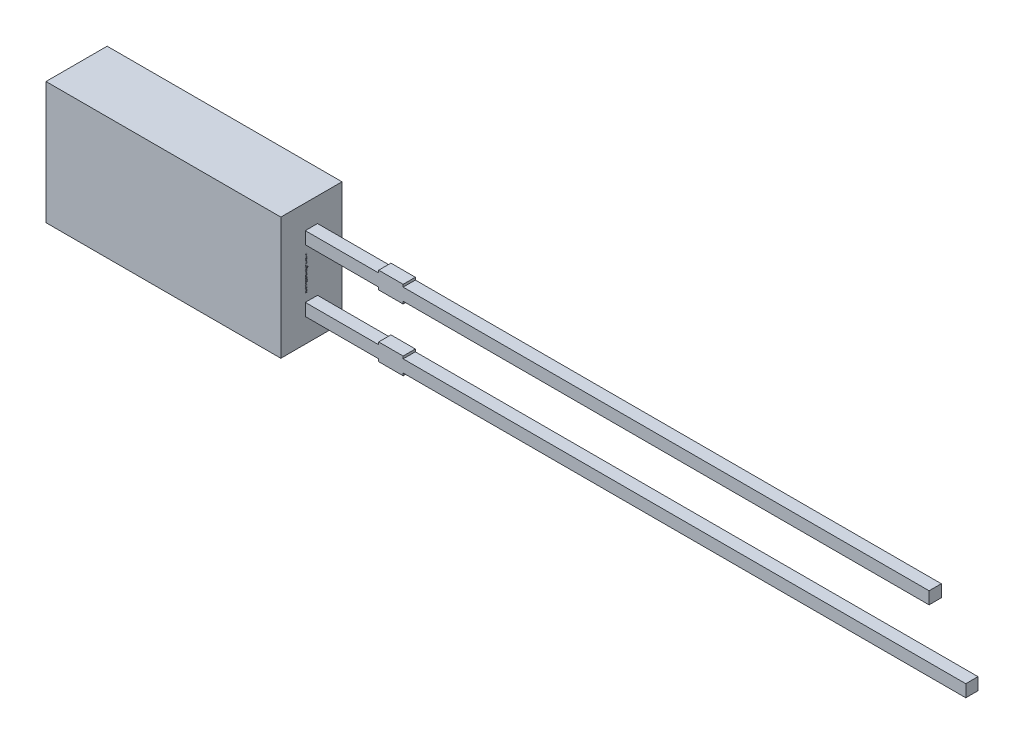
from build123d import *

# Parameters (mm, degrees)
SKETCH1_W          = 9.6
SKETCH1_H          = 5
EXTRUDE1_DEPTH     = 1.25
SKETCH1_4_W        = 3
SKETCH1_4_H        = 0.5
SKETCH1_4_W_2      = 1
SKETCH1_4_W_3      = 21.5
SKETCH1_4_H_2      = 0.1
SKETCH1_4_W_4      = 23
EXTRUDE2_DEPTH     = 0.25
SKETCH2_W          = 0.026582278
SKETCH2_H          = 0.025316456
CUT_EXTRUDE1_DEPTH = 0.01


with BuildPart() as part:
    # Sketch1 → Extrude1 (new body, symmetric)
    with BuildSketch(Plane.XY):
        Rectangle(SKETCH1_W, SKETCH1_H)
    extrude(amount=EXTRUDE1_DEPTH, both=True)

    # Sketch1_4 → Extrude2 (add, symmetric)
    with BuildSketch(Plane.XY):
        with Locations((6.3, 1.27)):
            Rectangle(SKETCH1_4_W, SKETCH1_4_H)
        with Locations((8.3, 1.27)):
            Rectangle(SKETCH1_4_W_2, SKETCH1_4_H)
        with Locations((19.55, 1.27)):
            Rectangle(SKETCH1_4_W_3, SKETCH1_4_H)
        with Locations((8.3, 1.57)):
            Rectangle(SKETCH1_4_W_2, SKETCH1_4_H_2)
        with Locations((8.3, 0.97)):
            Rectangle(SKETCH1_4_W_2, SKETCH1_4_H_2)
        with Locations((8.3, -1.27)):
            Rectangle(SKETCH1_4_W_2, SKETCH1_4_H)
        with Locations((8.3, -0.97)):
            Rectangle(SKETCH1_4_W_2, SKETCH1_4_H_2)
        with Locations((20.3, -1.27)):
            Rectangle(SKETCH1_4_W_4, SKETCH1_4_H)
        with Locations((6.3, -1.27)):
            Rectangle(SKETCH1_4_W, SKETCH1_4_H)
        with Locations((8.3, -1.57)):
            Rectangle(SKETCH1_4_W_2, SKETCH1_4_H_2)
    extrude(amount=EXTRUDE2_DEPTH, both=True)

    # Sketch2 → Cut-Extrude1 (cut)
    with BuildSketch(Plane(origin=(4.8, 0, 0), x_dir=(0, 0, -1), z_dir=(1, 0, 0))):
        Polygon((-0.175316456, 0.572151899), (-0.25, 0.595609177), (-0.25, 0.620352057), (-0.199663766, 0.636768196), (-0.25, 0.652294304), (-0.25, 0.678026108), (-0.175316456, 0.701265823), (-0.175316456, 0.676087816), (-0.226799842, 0.663093354), (-0.175316456, 0.646677215), (-0.175316456, 0.625178006), (-0.226799842, 0.608860759), (-0.175316456, 0.596044304), align=None)
        Polygon((-0.175316456, 0.437974684), (-0.25, 0.461431962), (-0.25, 0.486174842), (-0.199663766, 0.502590981), (-0.25, 0.518117089), (-0.25, 0.543848892), (-0.175316456, 0.567088608), (-0.175316456, 0.541910601), (-0.226799842, 0.528916139), (-0.175316456, 0.5125), (-0.175316456, 0.491000791), (-0.226799842, 0.474683544), (-0.175316456, 0.461867089), align=None)
        Polygon((-0.175316456, 0.303797468), (-0.25, 0.327254747), (-0.25, 0.351997627), (-0.199663766, 0.368413766), (-0.25, 0.383939873), (-0.25, 0.409671677), (-0.175316456, 0.432911392), (-0.175316456, 0.407733386), (-0.226799842, 0.394738924), (-0.175316456, 0.378322785), (-0.175316456, 0.356823576), (-0.226799842, 0.340506329), (-0.175316456, 0.327689873), align=None)
        with Locations((-0.236708861, 0.275949367)):
            Rectangle(SKETCH2_W, SKETCH2_H)
        with BuildLine():
            add(Edge.make_bspline(
                [(-0.218829114, 0.159493671), (-0.220051248, 0.159530169), (-0.22245111, 0.15960184), (-0.225958798, 0.160211426), (-0.229283102, 0.161205393), (-0.232447248, 0.162577732), (-0.235416736, 0.164371189), (-0.238219628, 0.16655446), (-0.240824172, 0.169143343), (-0.243260547, 0.172090146), (-0.245442658, 0.175387089), (-0.247348691, 0.178984804), (-0.248943362, 0.18286483), (-0.250282428, 0.187013042), (-0.251270861, 0.191459588), (-0.251994849, 0.196177087), (-0.252468166, 0.201170514), (-0.252510134, 0.204594091), (-0.252531646, 0.206348892)],
                knots=[0, 0, 0, 0, 0.907312236, 1.78165839, 2.635367075, 3.479697475, 4.336364812, 5.205276731, 6.11257575, 7.058770404, 8.040786331, 9.044147278, 10.078219212, 11.153049307, 12.278104542, 13.457648573, 14.696882856, 16, 16, 16, 16], degree=3))
            add(Edge.make_bspline(
                [(-0.252531646, 0.206348892), (-0.252507574, 0.208367148), (-0.252460949, 0.21227633), (-0.25203235, 0.217939855), (-0.251386211, 0.223207892), (-0.250419669, 0.228103607), (-0.249218904, 0.232708206), (-0.247927612, 0.237141474), (-0.246463197, 0.241422786), (-0.245363039, 0.244195876), (-0.244818038, 0.24556962)],
                knots=[0, 0, 0, 0, 1.203215828, 2.33052265, 3.384689099, 4.366106119, 5.303329643, 6.221311756, 7.118865988, 8, 8, 8, 8], degree=3))
            Line((-0.244818038, 0.24556962), (-0.220886076, 0.24556962))
            Line((-0.220886076, 0.24556962), (-0.220886076, 0.242721519))
            add(Edge.make_bspline(
                [(-0.220886076, 0.242721519), (-0.221967531, 0.241356205), (-0.224124092, 0.238633592), (-0.226886697, 0.234200359), (-0.22928886, 0.229552713), (-0.231262862, 0.224707243), (-0.232849186, 0.219810398), (-0.233942713, 0.21493502), (-0.234690062, 0.210169433), (-0.234770569, 0.207010864), (-0.234810127, 0.205458861)],
                knots=[0, 0, 0, 0, 1.030622468, 2.055194264, 3.087043286, 4.125157485, 5.149848264, 6.130935704, 7.081611712, 8, 8, 8, 8], degree=3))
            add(Edge.make_bspline(
                [(-0.234810127, 0.205458861), (-0.234809232, 0.205030082), (-0.234807317, 0.2041121), (-0.234678474, 0.202644063), (-0.234585311, 0.200985464), (-0.234376093, 0.199206598), (-0.23415751, 0.197415781), (-0.23377719, 0.195761121), (-0.233415351, 0.194257482), (-0.233047173, 0.193351), (-0.232871835, 0.192919304)],
                knots=[0, 0, 0, 0, 0.806378557, 1.726393851, 2.771014456, 3.931269413, 5.096090628, 6.161710732, 7.124547685, 8, 8, 8, 8], degree=3))
            add(Edge.make_bspline(
                [(-0.232871835, 0.192919304), (-0.232644012, 0.192439517), (-0.23219629, 0.191496634), (-0.231378683, 0.190201714), (-0.230507381, 0.189019042), (-0.229541962, 0.187957582), (-0.228364053, 0.187107314), (-0.226963197, 0.186479113), (-0.225312897, 0.186136019), (-0.224137886, 0.186096725), (-0.223516614, 0.186075949)],
                knots=[0, 0, 0, 0, 1.024407818, 2.013179384, 2.949802342, 3.859052226, 4.77034807, 5.732977883, 6.801339628, 8, 8, 8, 8], degree=3))
            add(Edge.make_bspline(
                [(-0.223516614, 0.186075949), (-0.222970718, 0.186107391), (-0.221897325, 0.186169215), (-0.220369329, 0.186751006), (-0.218947452, 0.187633905), (-0.217686737, 0.188920927), (-0.216529299, 0.190515003), (-0.215559002, 0.19247074), (-0.214678928, 0.194723719), (-0.214261659, 0.196368178), (-0.214042722, 0.197231013)],
                knots=[0, 0, 0, 0, 0.825212765, 1.622611382, 2.449701629, 3.348069183, 4.336544339, 5.428209675, 6.6506027, 8, 8, 8, 8], degree=3))
            add(Edge.make_bspline(
                [(-0.214042722, 0.197231013), (-0.213594981, 0.19919974), (-0.212677791, 0.203232648), (-0.211530684, 0.209380757), (-0.210264611, 0.215510984), (-0.20905507, 0.219469696), (-0.20846519, 0.221400316)],
                knots=[0, 0, 0, 0, 0.976104583, 1.999535498, 3.024395274, 4, 4, 4, 4], degree=3))
            add(Edge.make_bspline(
                [(-0.20846519, 0.221400316), (-0.208112197, 0.222438832), (-0.207425064, 0.224460401), (-0.206263439, 0.227351945), (-0.204993487, 0.230013057), (-0.203638356, 0.232453168), (-0.202164358, 0.23465249), (-0.200630968, 0.236647679), (-0.198977131, 0.238391205), (-0.197245211, 0.239938889), (-0.195393209, 0.241262203), (-0.193449072, 0.242416954), (-0.191388607, 0.243392589), (-0.189227318, 0.244201473), (-0.18694845, 0.244818545), (-0.184571576, 0.245239801), (-0.182088216, 0.24553819), (-0.180393863, 0.245559001), (-0.179529272, 0.24556962)],
                knots=[0, 0, 0, 0, 1.287286806, 2.505824366, 3.654938963, 4.74627059, 5.778586806, 6.75996495, 7.696030012, 8.595059759, 9.482019644, 10.363222407, 11.245851011, 12.154256429, 13.068444161, 14.012503255, 14.985824751, 16, 16, 16, 16], degree=3))
            add(Edge.make_bspline(
                [(-0.179529272, 0.24556962), (-0.178373127, 0.245532318), (-0.176097855, 0.245458909), (-0.172768811, 0.24485748), (-0.169620074, 0.24383089), (-0.166616611, 0.242444827), (-0.163803525, 0.240616199), (-0.161124978, 0.238431404), (-0.158653386, 0.235807357), (-0.156353053, 0.232830235), (-0.154273654, 0.229542851), (-0.152443098, 0.226003867), (-0.150906446, 0.222234578), (-0.149632552, 0.218249032), (-0.148677881, 0.214030563), (-0.14795895, 0.20959333), (-0.147545768, 0.204919541), (-0.147494518, 0.20172812), (-0.147468354, 0.200098892)],
                knots=[0, 0, 0, 0, 0.894990994, 1.761326291, 2.609044902, 3.454222546, 4.315366365, 5.200560057, 6.125081389, 7.100429509, 8.110379559, 9.133447974, 10.182136699, 11.259192205, 12.370181258, 13.528580438, 14.738335141, 16, 16, 16, 16], degree=3))
            add(Edge.make_bspline(
                [(-0.147468354, 0.200098892), (-0.147490546, 0.198430205), (-0.147534891, 0.19509566), (-0.147912869, 0.190114218), (-0.148468097, 0.185153716), (-0.149309803, 0.180289886), (-0.15028622, 0.175599331), (-0.151382015, 0.171186095), (-0.15261998, 0.167106634), (-0.153574325, 0.16453297), (-0.15403481, 0.163291139)],
                knots=[0, 0, 0, 0, 1.065403572, 2.129000689, 3.188532477, 4.251604565, 5.279552602, 6.247508681, 7.154397237, 8, 8, 8, 8], degree=3))
            Line((-0.15403481, 0.163291139), (-0.176582278, 0.163291139))
            Line((-0.176582278, 0.163291139), (-0.176582278, 0.166119462))
            add(Edge.make_bspline(
                [(-0.176582278, 0.166119462), (-0.175781932, 0.167192367), (-0.174145202, 0.169386485), (-0.17206153, 0.173046122), (-0.170103664, 0.177004358), (-0.168419505, 0.181283188), (-0.166960024, 0.185742216), (-0.165940858, 0.190325174), (-0.165299048, 0.194951338), (-0.165226273, 0.198053049), (-0.165189873, 0.19960443)],
                knots=[0, 0, 0, 0, 0.892283326, 1.824742884, 2.804416662, 3.836872171, 4.8899239, 5.931447339, 6.965372909, 8, 8, 8, 8], degree=3))
            add(Edge.make_bspline(
                [(-0.165189873, 0.19960443), (-0.165211326, 0.200700098), (-0.165254228, 0.202891315), (-0.165644912, 0.206159523), (-0.166275806, 0.209401584), (-0.167095088, 0.211442107), (-0.167503956, 0.212460443)],
                knots=[0, 0, 0, 0, 0.999146175, 1.998183711, 3.000980573, 4, 4, 4, 4], degree=3))
            add(Edge.make_bspline(
                [(-0.167503956, 0.212460443), (-0.167705423, 0.212893946), (-0.168108222, 0.213760664), (-0.168880786, 0.214967308), (-0.169809597, 0.216071977), (-0.170861589, 0.217064055), (-0.172017962, 0.217932452), (-0.173292788, 0.218547803), (-0.174655703, 0.218923676), (-0.175590934, 0.218965835), (-0.176068038, 0.218987342)],
                knots=[0, 0, 0, 0, 1.00524851, 2.009826503, 3.004679593, 4.035271301, 5.048246368, 6.034938417, 6.997532266, 8, 8, 8, 8], degree=3))
            add(Edge.make_bspline(
                [(-0.176068038, 0.218987342), (-0.176706203, 0.218952904), (-0.177925679, 0.218887095), (-0.179641475, 0.218280511), (-0.181119909, 0.217295678), (-0.182114829, 0.216135073), (-0.182812267, 0.215017943), (-0.183322777, 0.213982284), (-0.183806136, 0.212773057), (-0.184303605, 0.211401809), (-0.184794792, 0.209865482), (-0.185270339, 0.208156925), (-0.185719635, 0.206274208), (-0.186005825, 0.204958333), (-0.186155063, 0.204272152)],
                knots=[0, 0, 0, 0, 1.173816843, 2.243057204, 3.312297565, 4.415174738, 5.03266065, 5.73970059, 6.541434878, 7.433956553, 8.430083051, 9.515931566, 10.70464786, 12, 12, 12, 12], degree=3))
            add(Edge.make_bspline(
                [(-0.186155063, 0.204272152), (-0.186531125, 0.202439363), (-0.187270003, 0.198838337), (-0.188373491, 0.193437153), (-0.18964846, 0.18793438), (-0.190797263, 0.184269053), (-0.191396361, 0.182357595)],
                knots=[0, 0, 0, 0, 0.995744513, 1.956417928, 2.934277412, 4, 4, 4, 4], degree=3))
            add(Edge.make_bspline(
                [(-0.191396361, 0.182357595), (-0.191715605, 0.181411041), (-0.192340097, 0.179559428), (-0.19342638, 0.176918797), (-0.194600363, 0.174471738), (-0.195841894, 0.172204706), (-0.19718586, 0.170130736), (-0.198608507, 0.168236053), (-0.200135416, 0.166552235), (-0.201748644, 0.16505467), (-0.203458744, 0.16373551), (-0.205297817, 0.162603212), (-0.207246619, 0.161630984), (-0.209332819, 0.160861379), (-0.211527406, 0.160243358), (-0.213858774, 0.159820261), (-0.21630315, 0.159526278), (-0.217977728, 0.159504661), (-0.218829114, 0.159493671)],
                knots=[0, 0, 0, 0, 1.237467875, 2.420686895, 3.535046182, 4.599015201, 5.620884487, 6.594603852, 7.531477383, 8.433220087, 9.318759595, 10.202828513, 11.105163009, 12.01247538, 12.953896178, 13.926381251, 14.945733412, 16, 16, 16, 16], degree=3))
        make_face()
        with BuildLine():
            Line((-0.25, 0.067088608), (-0.25, 0.091139241))
            Line((-0.25, 0.091139241), (-0.242167722, 0.091139241))
            add(Edge.make_bspline(
                [(-0.242167722, 0.091139241), (-0.24297628, 0.092232549), (-0.244535168, 0.094340433), (-0.246615386, 0.097513458), (-0.248390652, 0.100539548), (-0.249949873, 0.103453039), (-0.251125258, 0.106475242), (-0.251953324, 0.109706756), (-0.252453097, 0.113209581), (-0.252504881, 0.115636475), (-0.252531646, 0.116890823)],
                knots=[0, 0, 0, 0, 1.150872466, 2.218865267, 3.209461834, 4.120482262, 5.012764827, 5.946708227, 6.938749913, 8, 8, 8, 8], degree=3))
            add(Edge.make_bspline(
                [(-0.252531646, 0.116890823), (-0.252508927, 0.117907175), (-0.252464686, 0.119886305), (-0.252119808, 0.122763545), (-0.251582157, 0.125471173), (-0.250774566, 0.127986213), (-0.249808763, 0.130350202), (-0.248528805, 0.132487752), (-0.247098631, 0.134491354), (-0.245391585, 0.136273026), (-0.243493852, 0.137888648), (-0.241361392, 0.139271198), (-0.239028466, 0.140448909), (-0.236476612, 0.141390006), (-0.233718309, 0.142145096), (-0.230739061, 0.142669028), (-0.227551934, 0.142989621), (-0.225356803, 0.14302156), (-0.224228639, 0.143037975)],
                knots=[0, 0, 0, 0, 1.109008058, 2.159558935, 3.158726032, 4.116861086, 5.039058877, 5.938775559, 6.82970133, 7.720510853, 8.624361809, 9.544451588, 10.487360536, 11.471068125, 12.508000841, 13.604731202, 14.768976642, 16, 16, 16, 16], degree=3))
            Line((-0.224228639, 0.143037975), (-0.175316456, 0.143037975))
            Line((-0.175316456, 0.143037975), (-0.175316456, 0.118987342))
            Line((-0.175316456, 0.118987342), (-0.21289557, 0.118987342))
            add(Edge.make_bspline(
                [(-0.21289557, 0.118987342), (-0.213812041, 0.118985706), (-0.215566256, 0.118982576), (-0.218072063, 0.118900237), (-0.220340235, 0.118779336), (-0.222382264, 0.118640631), (-0.224229015, 0.118387615), (-0.225895176, 0.118009906), (-0.227414778, 0.11753908), (-0.228321479, 0.117074761), (-0.228757911, 0.116851266)],
                knots=[0, 0, 0, 0, 1.361401701, 2.605856924, 3.723918663, 4.735739235, 5.645738665, 6.489217889, 7.27279937, 8, 8, 8, 8], degree=3))
            add(Edge.make_bspline(
                [(-0.228757911, 0.116851266), (-0.229156626, 0.116621259), (-0.229940466, 0.116169086), (-0.230946644, 0.115248796), (-0.231790911, 0.114170053), (-0.23244694, 0.112892449), (-0.232945889, 0.111405901), (-0.233286125, 0.109677971), (-0.233501627, 0.107692609), (-0.233529535, 0.106283591), (-0.233544304, 0.105537975)],
                knots=[0, 0, 0, 0, 0.849138082, 1.669332372, 2.503455908, 3.370611167, 4.311442699, 5.394692208, 6.621337967, 8, 8, 8, 8], degree=3))
            add(Edge.make_bspline(
                [(-0.233544304, 0.105537975), (-0.233526947, 0.104996691), (-0.233491259, 0.103883773), (-0.233258814, 0.102172461), (-0.232902139, 0.100375884), (-0.232242283, 0.097861301), (-0.231056104, 0.094694674), (-0.229701697, 0.092335372), (-0.229015032, 0.091139241)],
                knots=[0, 0, 0, 0, 0.638127216, 1.312033637, 2.033062677, 2.79661882, 4.375931797, 6, 6, 6, 6], degree=3))
            Line((-0.229015032, 0.091139241), (-0.175316456, 0.091139241))
            Line((-0.175316456, 0.091139241), (-0.175316456, 0.067088608))
            Line((-0.175316456, 0.067088608), (-0.25, 0.067088608))
        make_face()
        with BuildLine():
            Line((-0.25, -0.030379747), (-0.25, -0.006329114))
            Line((-0.25, -0.006329114), (-0.212420886, -0.006329114))
            add(Edge.make_bspline(
                [(-0.212420886, -0.006329114), (-0.210890843, -0.0063046), (-0.207839818, -0.006255716), (-0.204077407, -0.005973592), (-0.201235083, -0.00559507), (-0.199397202, -0.005225415), (-0.197849063, -0.004793715), (-0.196963303, -0.004381435), (-0.196558544, -0.004193038)],
                knots=[0, 0, 0, 0, 1.709124929, 3.408128882, 4.211124727, 4.91016634, 5.501986363, 6, 6, 6, 6], degree=3))
            add(Edge.make_bspline(
                [(-0.196558544, -0.004193038), (-0.196160491, -0.003948575), (-0.195380051, -0.003469272), (-0.194367038, -0.002531948), (-0.193538197, -0.001438061), (-0.192856647, -0.000167292), (-0.192386066, 0.001323905), (-0.191992836, 0.003040645), (-0.191825927, 0.005027263), (-0.191790767, 0.006434533), (-0.191772152, 0.007179589)],
                knots=[0, 0, 0, 0, 0.86006424, 1.686277094, 2.52783008, 3.38194165, 4.331801563, 5.402842185, 6.624978739, 8, 8, 8, 8], degree=3))
            add(Edge.make_bspline(
                [(-0.191772152, 0.007179589), (-0.191828889, 0.00831141), (-0.191944743, 0.010622505), (-0.19265625, 0.013484698), (-0.193475209, 0.015815302), (-0.19423404, 0.017667827), (-0.195205482, 0.019576457), (-0.195927304, 0.020855869), (-0.196301424, 0.021518987)],
                knots=[0, 0, 0, 0, 1.338371478, 2.732853438, 3.468019217, 4.261884641, 5.099136535, 6, 6, 6, 6], degree=3))
            Line((-0.196301424, 0.021518987), (-0.25, 0.021518987))
            Line((-0.25, 0.021518987), (-0.25, 0.04556962))
            Line((-0.25, 0.04556962), (-0.175316456, 0.04556962))
            Line((-0.175316456, 0.04556962), (-0.175316456, 0.021518987))
            Line((-0.175316456, 0.021518987), (-0.183148734, 0.021518987))
            add(Edge.make_bspline(
                [(-0.183148734, 0.021518987), (-0.182342583, 0.020461581), (-0.18077336, 0.018403276), (-0.17873294, 0.015224038), (-0.176934171, 0.01214014), (-0.175421354, 0.009087131), (-0.174214579, 0.005972176), (-0.17340359, 0.002709417), (-0.172859787, -0.000706989), (-0.172810094, -0.003043704), (-0.17278481, -0.004232595)],
                knots=[0, 0, 0, 0, 1.126119141, 2.192057864, 3.198061997, 4.149848529, 5.076251285, 6.021887753, 6.99356175, 8, 8, 8, 8], degree=3))
            add(Edge.make_bspline(
                [(-0.17278481, -0.004232595), (-0.172810199, -0.005228866), (-0.172859763, -0.007173765), (-0.173169473, -0.010008526), (-0.173720137, -0.012679947), (-0.174517966, -0.015172221), (-0.175503578, -0.017514841), (-0.176735093, -0.019676785), (-0.178193516, -0.021668856), (-0.179854519, -0.023497257), (-0.181744245, -0.025128075), (-0.18386151, -0.026545111), (-0.186204606, -0.027725092), (-0.188764915, -0.028695805), (-0.191530024, -0.029470228), (-0.19452599, -0.029985359), (-0.197730169, -0.030339143), (-0.199946212, -0.030365941), (-0.201087816, -0.030379747)],
                knots=[0, 0, 0, 0, 1.08848837, 2.124922927, 3.110950502, 4.063144162, 4.979605775, 5.882838355, 6.774625441, 7.671951181, 8.57587277, 9.494821853, 10.448322275, 11.435533005, 12.482327682, 13.580118324, 14.753386918, 16, 16, 16, 16], degree=3))
            Line((-0.201087816, -0.030379747), (-0.25, -0.030379747))
        make_face()
        Polygon((-0.25, -0.125316456), (-0.25, -0.053164557), (-0.15, -0.053164557), (-0.15, -0.078481013), (-0.231012658, -0.078481013), (-0.231012658, -0.125316456), align=None)
        Polygon((-0.25, -0.212658228), (-0.25, -0.140506329), (-0.15, -0.140506329), (-0.15, -0.212658228), (-0.168987342, -0.212658228), (-0.168987342, -0.165822785), (-0.186708861, -0.165822785), (-0.186708861, -0.208860759), (-0.205696203, -0.208860759), (-0.205696203, -0.165822785), (-0.231012658, -0.165822785), (-0.231012658, -0.212658228), align=None)
        with BuildLine():
            add(Edge.make_bspline(
                [(-0.200098892, -0.329113924), (-0.201246581, -0.329094609), (-0.203519467, -0.329056357), (-0.206884274, -0.328761165), (-0.210149949, -0.32823514), (-0.213334198, -0.327555959), (-0.216413126, -0.326633453), (-0.219420703, -0.325551739), (-0.222326196, -0.324242093), (-0.225127631, -0.322737241), (-0.227799734, -0.321087768), (-0.230319942, -0.319313019), (-0.23270316, -0.31746724), (-0.234898054, -0.315477927), (-0.236940074, -0.313398746), (-0.238830888, -0.311223217), (-0.240534319, -0.308918153), (-0.241557203, -0.30731099), (-0.242068829, -0.30650712)],
                knots=[0, 0, 0, 0, 1.105570398, 2.18947457, 3.250358341, 4.290584537, 5.323553275, 6.344225964, 7.367641686, 8.3905646, 9.405808457, 10.390761353, 11.358902336, 12.307789878, 13.241960776, 14.165076779, 15.082208636, 16, 16, 16, 16], degree=3))
            add(Edge.make_bspline(
                [(-0.242068829, -0.30650712), (-0.242780968, -0.305267892), (-0.244208881, -0.302783112), (-0.245877472, -0.298799278), (-0.247281588, -0.294673795), (-0.248336012, -0.290323409), (-0.249063056, -0.285676399), (-0.249623862, -0.28067499), (-0.249925622, -0.275267401), (-0.249974642, -0.271532506), (-0.25, -0.269600475)],
                knots=[0, 0, 0, 0, 0.896288622, 1.797150563, 2.705281913, 3.629615989, 4.602417572, 5.655716007, 6.787320449, 8, 8, 8, 8], degree=3))
            Line((-0.25, -0.269600475), (-0.25, -0.234177215))
            Line((-0.25, -0.234177215), (-0.15, -0.234177215))
            Line((-0.15, -0.234177215), (-0.15, -0.270609177))
            add(Edge.make_bspline(
                [(-0.15, -0.270609177), (-0.150016611, -0.272587909), (-0.150048652, -0.276404637), (-0.150466242, -0.281921476), (-0.151063066, -0.287026684), (-0.151987937, -0.291712032), (-0.153103282, -0.296012037), (-0.154462411, -0.299937513), (-0.155961118, -0.303549287), (-0.157234811, -0.305728129), (-0.157852057, -0.306784019)],
                knots=[0, 0, 0, 0, 1.267175336, 2.444223962, 3.542125549, 4.557526608, 5.500936977, 6.385043188, 7.217374394, 8, 8, 8, 8], degree=3))
            add(Edge.make_bspline(
                [(-0.157852057, -0.306784019), (-0.158388598, -0.307634972), (-0.159455511, -0.309327097), (-0.161237363, -0.311728312), (-0.16319344, -0.313957739), (-0.165245259, -0.316086242), (-0.167448146, -0.318066059), (-0.169786853, -0.319909259), (-0.172264947, -0.321613076), (-0.174874416, -0.323171039), (-0.177604468, -0.324591854), (-0.180477527, -0.32578116), (-0.183456057, -0.326830509), (-0.186565019, -0.327636046), (-0.189772856, -0.32833396), (-0.1931142, -0.328768694), (-0.196566688, -0.329055305), (-0.198911578, -0.32909422), (-0.200098892, -0.329113924)],
                knots=[0, 0, 0, 0, 0.964065863, 1.917049184, 2.86229036, 3.805247319, 4.749389377, 5.698846072, 6.657678277, 7.629829384, 8.610569287, 9.604676042, 10.607940105, 11.6349849, 12.681042988, 13.752616828, 14.862056989, 16, 16, 16, 16], degree=3))
        make_face()
        with BuildLine():
            add(Edge.make_bspline(
                [(-0.199940665, -0.302531646), (-0.199135905, -0.302521405), (-0.197557321, -0.302501317), (-0.195241806, -0.30230975), (-0.193012156, -0.302050694), (-0.190877464, -0.30161964), (-0.188817893, -0.301119993), (-0.186860399, -0.300477843), (-0.184980826, -0.299753447), (-0.183203337, -0.298871809), (-0.181494955, -0.297898172), (-0.17990944, -0.296750679), (-0.178396553, -0.295502341), (-0.176968569, -0.294124054), (-0.175662673, -0.292581114), (-0.174432597, -0.290921012), (-0.173304271, -0.289120654), (-0.172644221, -0.287847665), (-0.172310127, -0.287203323)],
                knots=[0, 0, 0, 0, 1.152093354, 2.259898929, 3.325467225, 4.364140538, 5.376172865, 6.358396836, 7.312077728, 8.257828931, 9.196960457, 10.124297759, 11.056236784, 12.004246951, 12.961658638, 13.947279359, 14.960983522, 16, 16, 16, 16], degree=3))
            add(Edge.make_bspline(
                [(-0.172310127, -0.287203323), (-0.172003415, -0.286528425), (-0.17139549, -0.285190731), (-0.170664298, -0.283119908), (-0.170091462, -0.281030524), (-0.169660604, -0.278828925), (-0.169338673, -0.276359165), (-0.169141415, -0.273433583), (-0.168999245, -0.269977674), (-0.168991494, -0.267490959), (-0.168987342, -0.266159019)],
                knots=[0, 0, 0, 0, 0.826967603, 1.639107464, 2.447640171, 3.242670507, 4.14065217, 5.225198036, 6.513753944, 8, 8, 8, 8], degree=3))
            Line((-0.168987342, -0.266159019), (-0.168987342, -0.259493671))
            Line((-0.168987342, -0.259493671), (-0.231012658, -0.259493671))
            Line((-0.231012658, -0.259493671), (-0.231012658, -0.266159019))
            add(Edge.make_bspline(
                [(-0.231012658, -0.266159019), (-0.231007909, -0.266917226), (-0.230998739, -0.268380991), (-0.230955677, -0.270497235), (-0.230908789, -0.272463031), (-0.230792327, -0.274267902), (-0.230719681, -0.275926587), (-0.230541302, -0.277413368), (-0.230399122, -0.278755857), (-0.230131399, -0.280323454), (-0.229715216, -0.28217662), (-0.229037037, -0.28433788), (-0.228186642, -0.286478414), (-0.227501675, -0.287866987), (-0.227155854, -0.288568038)],
                knots=[0, 0, 0, 0, 1.186793418, 2.291178421, 3.313283093, 4.264083014, 5.122158624, 5.910777728, 6.607099052, 7.234812932, 8.398911528, 9.577194775, 10.776795607, 12, 12, 12, 12], degree=3))
            add(Edge.make_bspline(
                [(-0.227155854, -0.288568038), (-0.226814338, -0.289153154), (-0.226140824, -0.29030708), (-0.22500675, -0.291930584), (-0.223799025, -0.293438302), (-0.222510574, -0.294834314), (-0.221122333, -0.296097614), (-0.219655791, -0.297249633), (-0.218107813, -0.298280082), (-0.215914295, -0.299515471), (-0.212883358, -0.300738716), (-0.208915972, -0.301778259), (-0.204556209, -0.30241513), (-0.201518591, -0.302491812), (-0.199940665, -0.302531646)],
                knots=[0, 0, 0, 0, 0.755160452, 1.489275589, 2.205657296, 2.907868421, 3.605098304, 4.296256403, 4.985378686, 5.676536785, 7.100390329, 8.614249252, 10.241231541, 12, 12, 12, 12], degree=3))
        make_face(mode=Mode.SUBTRACT)
        with Locations((-0.236708861, -0.360759494)):
            Rectangle(SKETCH2_W, SKETCH2_H)
        with BuildLine():
            add(Edge.make_bspline(
                [(-0.252531646, -0.435403481), (-0.252509834, -0.433813368), (-0.252467023, -0.430692232), (-0.251990106, -0.42612089), (-0.25127241, -0.421755717), (-0.250251504, -0.417609409), (-0.248904008, -0.413695618), (-0.247251072, -0.41003198), (-0.245265888, -0.406625123), (-0.243686679, -0.404566476), (-0.242899525, -0.403540348)],
                knots=[0, 0, 0, 0, 1.123670284, 2.205584497, 3.245308791, 4.249063313, 5.220352711, 6.167273909, 7.086481357, 8, 8, 8, 8], degree=3))
            add(Edge.make_bspline(
                [(-0.242899525, -0.403540348), (-0.242044751, -0.402588601), (-0.240338508, -0.400688786), (-0.237367081, -0.398222853), (-0.234084037, -0.396099767), (-0.230481815, -0.394314215), (-0.226565086, -0.392883291), (-0.222320424, -0.391860157), (-0.217759643, -0.391240912), (-0.21461171, -0.391173746), (-0.212994462, -0.391139241)],
                knots=[0, 0, 0, 0, 0.916457077, 1.82937027, 2.759194969, 3.714948755, 4.706655623, 5.743329475, 6.840637961, 8, 8, 8, 8], degree=3))
            add(Edge.make_bspline(
                [(-0.212994462, -0.391139241), (-0.211291235, -0.391178001), (-0.207990155, -0.391253124), (-0.203217967, -0.391916883), (-0.198800287, -0.392986496), (-0.194748378, -0.394524054), (-0.191055187, -0.396454496), (-0.187683352, -0.398718989), (-0.184640428, -0.401339514), (-0.182894988, -0.403346653), (-0.182021361, -0.404351266)],
                knots=[0, 0, 0, 0, 1.171797512, 2.271099083, 3.308930235, 4.294129479, 5.24602549, 6.17106565, 7.084581485, 8, 8, 8, 8], degree=3))
            add(Edge.make_bspline(
                [(-0.182021361, -0.404351266), (-0.181252774, -0.405377136), (-0.179706318, -0.407441268), (-0.177805619, -0.410844773), (-0.176210833, -0.414467988), (-0.174963188, -0.418297559), (-0.174009283, -0.422270367), (-0.173285439, -0.426330027), (-0.172864881, -0.43047628), (-0.172811629, -0.43326648), (-0.17278481, -0.434671677)],
                knots=[0, 0, 0, 0, 0.952130878, 1.915761808, 2.890227217, 3.891541892, 4.905612075, 5.925811839, 6.955400088, 8, 8, 8, 8], degree=3))
            add(Edge.make_bspline(
                [(-0.17278481, -0.434671677), (-0.172801812, -0.435918396), (-0.172835245, -0.438369867), (-0.173157354, -0.441970914), (-0.173690473, -0.445425455), (-0.174429076, -0.448730387), (-0.175320679, -0.451904334), (-0.17635982, -0.454954511), (-0.177493088, -0.457914321), (-0.178377623, -0.45981489), (-0.178817247, -0.460759494)],
                knots=[0, 0, 0, 0, 1.107648782, 2.178012834, 3.209595929, 4.211695017, 5.185427128, 6.137685403, 7.07440854, 8, 8, 8, 8], degree=3))
            Line((-0.178817247, -0.460759494), (-0.199367089, -0.460759494))
            Line((-0.199367089, -0.460759494), (-0.199367089, -0.45741693))
            add(Edge.make_bspline(
                [(-0.199367089, -0.45741693), (-0.198949869, -0.456917386), (-0.198048154, -0.45583775), (-0.196627402, -0.454051335), (-0.195097809, -0.451902393), (-0.194205863, -0.450248857), (-0.193730222, -0.449367089)],
                knots=[0, 0, 0, 0, 0.792826818, 1.713491785, 2.780691913, 4, 4, 4, 4], degree=3))
            add(Edge.make_bspline(
                [(-0.193730222, -0.449367089), (-0.193288264, -0.448439154), (-0.192382404, -0.446537209), (-0.19154957, -0.443981204), (-0.190981844, -0.441789202), (-0.190725422, -0.439971666), (-0.190535861, -0.438038046), (-0.190516354, -0.436702803), (-0.190506329, -0.436016614)],
                knots=[0, 0, 0, 0, 1.332524827, 2.731214173, 3.480270227, 4.267952375, 5.109889624, 6, 6, 6, 6], degree=3))
            add(Edge.make_bspline(
                [(-0.190506329, -0.436016614), (-0.190525879, -0.435251058), (-0.190563765, -0.433767448), (-0.190840821, -0.431605939), (-0.191319079, -0.429587528), (-0.191959179, -0.427684306), (-0.192846792, -0.425946243), (-0.193880429, -0.424319403), (-0.195106231, -0.422827143), (-0.196547173, -0.421507882), (-0.198127102, -0.420315156), (-0.199861217, -0.419295954), (-0.201707816, -0.418383498), (-0.203712265, -0.41768856), (-0.205841041, -0.417128822), (-0.208104161, -0.416739892), (-0.210503671, -0.416497934), (-0.212149979, -0.416470016), (-0.212994462, -0.416455696)],
                knots=[0, 0, 0, 0, 1.087302107, 2.107140881, 3.088415001, 4.030197574, 4.951552271, 5.852940509, 6.764198256, 7.685219758, 8.621679636, 9.570836121, 10.538340132, 11.542450476, 12.578202196, 13.66207107, 14.800746211, 16, 16, 16, 16], degree=3))
            add(Edge.make_bspline(
                [(-0.212994462, -0.416455696), (-0.213858618, -0.416470471), (-0.215537631, -0.416499177), (-0.217979242, -0.416732691), (-0.220260673, -0.417148582), (-0.222385993, -0.41771983), (-0.224352011, -0.418444178), (-0.226149408, -0.419349295), (-0.227806215, -0.420385652), (-0.229268827, -0.42163021), (-0.230585149, -0.422994093), (-0.231721283, -0.424508985), (-0.232669428, -0.426168224), (-0.233473891, -0.427950405), (-0.234052289, -0.429883445), (-0.234488981, -0.431939982), (-0.234777538, -0.434129537), (-0.234799101, -0.435639891), (-0.234810127, -0.436412184)],
                knots=[0, 0, 0, 0, 1.230336593, 2.390482092, 3.487897344, 4.52859895, 5.520747884, 6.465347575, 7.38981449, 8.296085817, 9.192433006, 10.084246191, 10.984321635, 11.908883871, 12.862027947, 13.850751296, 14.901019963, 16, 16, 16, 16], degree=3))
            add(Edge.make_bspline(
                [(-0.234810127, -0.436412184), (-0.234801999, -0.437138038), (-0.234786155, -0.438553063), (-0.234568078, -0.44061781), (-0.234292195, -0.442578718), (-0.233852787, -0.444414258), (-0.233310412, -0.446109524), (-0.232743906, -0.447669947), (-0.232139122, -0.449082395), (-0.231671567, -0.449943749), (-0.231447785, -0.450356013)],
                knots=[0, 0, 0, 0, 1.200823684, 2.340960236, 3.433630075, 4.476504061, 5.46014544, 6.378484521, 7.223905657, 8, 8, 8, 8], degree=3))
            add(Edge.make_bspline(
                [(-0.231447785, -0.450356013), (-0.23101789, -0.451056218), (-0.230186248, -0.452410785), (-0.228784682, -0.454249513), (-0.227370422, -0.455894382), (-0.226414205, -0.456918894), (-0.225949367, -0.45741693)],
                knots=[0, 0, 0, 0, 1.098601379, 2.125273733, 3.088655601, 4, 4, 4, 4], degree=3))
            Line((-0.225949367, -0.45741693), (-0.225949367, -0.460759494))
            Line((-0.225949367, -0.460759494), (-0.246657437, -0.460759494))
            add(Edge.make_bspline(
                [(-0.246657437, -0.460759494), (-0.247094931, -0.459814104), (-0.247970024, -0.457923097), (-0.249123896, -0.455008518), (-0.250092057, -0.452020545), (-0.250995137, -0.448972172), (-0.251683499, -0.445800089), (-0.252176622, -0.442477058), (-0.252477534, -0.43899556), (-0.252513362, -0.436617171), (-0.252531646, -0.435403481)],
                knots=[0, 0, 0, 0, 0.952012952, 1.904254716, 2.862729541, 3.822037426, 4.808956931, 5.82647221, 6.890850784, 8, 8, 8, 8], degree=3))
        make_face()
        with BuildLine():
            add(Edge.make_bspline(
                [(-0.212697785, -0.553164557), (-0.214202691, -0.553139862), (-0.217136157, -0.553091723), (-0.221407948, -0.552552407), (-0.225443946, -0.551739627), (-0.229231154, -0.550567096), (-0.232788429, -0.549086703), (-0.236078221, -0.547235764), (-0.239131451, -0.545064759), (-0.241921336, -0.542573722), (-0.244419846, -0.53977252), (-0.246615099, -0.536698338), (-0.248428541, -0.533324511), (-0.249940631, -0.5297102), (-0.251109866, -0.525825548), (-0.251922584, -0.521671329), (-0.252458054, -0.517254195), (-0.252506706, -0.514215776), (-0.252531646, -0.512658228)],
                knots=[0, 0, 0, 0, 1.120167703, 2.183507516, 3.201345984, 4.182878364, 5.131270247, 6.065524964, 6.98789854, 7.91635504, 8.84481154, 9.778033504, 10.722808862, 11.691211189, 12.691525459, 13.738229926, 14.840575679, 16, 16, 16, 16], degree=3))
            add(Edge.make_bspline(
                [(-0.252531646, -0.512658228), (-0.252506624, -0.511100707), (-0.252457811, -0.508062341), (-0.25192348, -0.503644832), (-0.251105529, -0.499485737), (-0.249949428, -0.49559643), (-0.248422879, -0.491987684), (-0.246615831, -0.488617817), (-0.244419638, -0.485544052), (-0.241921446, -0.482742566), (-0.239131219, -0.480252248), (-0.236079037, -0.478078657), (-0.232783083, -0.476236243), (-0.229240037, -0.474718389), (-0.225439199, -0.473585065), (-0.221408758, -0.472761602), (-0.217135938, -0.472225394), (-0.214202617, -0.472176819), (-0.212697785, -0.472151899)],
                knots=[0, 0, 0, 0, 1.15937715, 2.261678054, 3.308339936, 4.313313916, 5.277148057, 6.221884977, 7.155068972, 8.083487698, 9.011906424, 9.934242473, 10.868459181, 11.818729666, 12.798784262, 13.81658132, 14.879877871, 16, 16, 16, 16], degree=3))
            add(Edge.make_bspline(
                [(-0.212697785, -0.472151899), (-0.211186361, -0.472177022), (-0.208233351, -0.472226107), (-0.203934478, -0.472761477), (-0.199873828, -0.473579494), (-0.196065514, -0.474739526), (-0.192513914, -0.476255799), (-0.18921181, -0.478096824), (-0.186165235, -0.480293292), (-0.183375483, -0.48280279), (-0.180879102, -0.485614584), (-0.178706197, -0.488708516), (-0.176869539, -0.492060435), (-0.175347706, -0.495667634), (-0.174213141, -0.49955419), (-0.173395562, -0.503691132), (-0.17285749, -0.508088526), (-0.172809478, -0.511107264), (-0.17278481, -0.512658228)],
                knots=[0, 0, 0, 0, 1.124034801, 2.196132384, 3.217834281, 4.203147447, 5.152578239, 6.085969439, 7.010345409, 7.941219594, 8.872481455, 9.802010446, 10.748267785, 11.711250247, 12.709230373, 13.754967386, 14.846549946, 16, 16, 16, 16], degree=3))
            add(Edge.make_bspline(
                [(-0.17278481, -0.512658228), (-0.172809532, -0.514228966), (-0.172857665, -0.51728713), (-0.173393868, -0.521730542), (-0.174206873, -0.525904381), (-0.175373269, -0.529803006), (-0.176884682, -0.533428756), (-0.17871934, -0.536788831), (-0.180921398, -0.539860139), (-0.183428554, -0.542647393), (-0.186233956, -0.545127634), (-0.189283579, -0.54729655), (-0.192603295, -0.549103768), (-0.196158163, -0.550585538), (-0.199951933, -0.551757711), (-0.203986038, -0.552578696), (-0.208261035, -0.553084687), (-0.211193165, -0.553137471), (-0.212697785, -0.553164557)],
                knots=[0, 0, 0, 0, 1.167358552, 2.272800965, 3.322628764, 4.326027541, 5.29287265, 6.238482395, 7.166210353, 8.096447471, 9.020151799, 9.945039072, 10.873038967, 11.824425184, 12.804379233, 13.820580988, 14.881633558, 16, 16, 16, 16], degree=3))
        make_face()
        with BuildLine():
            add(Edge.make_bspline(
                [(-0.231190665, -0.523457278), (-0.230690658, -0.523812456), (-0.229673086, -0.524535285), (-0.227972663, -0.525405537), (-0.226150868, -0.526193542), (-0.224121587, -0.526811737), (-0.221819141, -0.527291059), (-0.219165549, -0.52760245), (-0.216130036, -0.527832094), (-0.213977323, -0.527842556), (-0.212836234, -0.527848101)],
                knots=[0, 0, 0, 0, 0.764956307, 1.556776596, 2.379454426, 3.241401993, 4.200532455, 5.312591107, 6.575484591, 8, 8, 8, 8], degree=3))
            add(Edge.make_bspline(
                [(-0.212836234, -0.527848101), (-0.211761353, -0.527830412), (-0.209701996, -0.527796522), (-0.206742233, -0.527610152), (-0.204058807, -0.527261478), (-0.201641411, -0.5267636), (-0.199470723, -0.526153829), (-0.19752836, -0.525427894), (-0.195809758, -0.524589376), (-0.194804527, -0.523903909), (-0.194323576, -0.523575949)],
                knots=[0, 0, 0, 0, 1.337076348, 2.561692668, 3.686680134, 4.69989255, 5.629188848, 6.488203485, 7.276684665, 8, 8, 8, 8], degree=3))
            add(Edge.make_bspline(
                [(-0.194323576, -0.523575949), (-0.193884293, -0.523238652), (-0.193022537, -0.522576962), (-0.191940352, -0.521400911), (-0.191042058, -0.520136352), (-0.190382017, -0.51875605), (-0.189862759, -0.517310883), (-0.189515923, -0.515802557), (-0.189287802, -0.514247405), (-0.189256424, -0.513193069), (-0.189240506, -0.512658228)],
                knots=[0, 0, 0, 0, 1.058684453, 2.076859345, 3.046867319, 4.017860406, 4.996047344, 5.981941452, 6.976284511, 8, 8, 8, 8], degree=3))
            add(Edge.make_bspline(
                [(-0.189240506, -0.512658228), (-0.189251453, -0.512130296), (-0.189272863, -0.511097679), (-0.189452545, -0.509595013), (-0.189747135, -0.508184065), (-0.190165068, -0.506844191), (-0.190760551, -0.505552217), (-0.191616975, -0.504317872), (-0.192692306, -0.503101936), (-0.193542825, -0.502363688), (-0.193987342, -0.501977848)],
                knots=[0, 0, 0, 0, 1.041978199, 2.038073998, 2.982578265, 3.884042198, 4.804014415, 5.778706634, 6.839057036, 8, 8, 8, 8], degree=3))
            add(Edge.make_bspline(
                [(-0.193987342, -0.501977848), (-0.194461968, -0.501644363), (-0.195460568, -0.500942719), (-0.197165089, -0.500059744), (-0.199127009, -0.49932839), (-0.20131075, -0.49863615), (-0.203781898, -0.498117886), (-0.206535176, -0.497717147), (-0.209589603, -0.497516433), (-0.21172182, -0.497484858), (-0.212836234, -0.497468354)],
                knots=[0, 0, 0, 0, 0.706185926, 1.485796665, 2.33004681, 3.254820698, 4.274138656, 5.402098861, 6.642194297, 8, 8, 8, 8], degree=3))
            add(Edge.make_bspline(
                [(-0.212836234, -0.497468354), (-0.213838698, -0.497477501), (-0.21577981, -0.497495212), (-0.218586195, -0.497694126), (-0.221190128, -0.498022802), (-0.22358016, -0.498499446), (-0.225765057, -0.49907369), (-0.227716716, -0.499821164), (-0.229471774, -0.500644638), (-0.230499515, -0.501344976), (-0.23099288, -0.501681171)],
                knots=[0, 0, 0, 0, 1.270915159, 2.460926195, 3.565223763, 4.596447547, 5.549594966, 6.425286377, 7.244063354, 8, 8, 8, 8], degree=3))
            add(Edge.make_bspline(
                [(-0.23099288, -0.501681171), (-0.231409366, -0.502021731), (-0.232230494, -0.502693168), (-0.233314509, -0.503842086), (-0.23417586, -0.505125798), (-0.234906348, -0.506477001), (-0.235435594, -0.507938804), (-0.235812201, -0.509490696), (-0.236027955, -0.511142431), (-0.236059682, -0.512275225), (-0.236075949, -0.512856013)],
                knots=[0, 0, 0, 0, 1.011121112, 1.993489184, 2.956264801, 3.910060304, 4.874908638, 5.87009835, 6.907993364, 8, 8, 8, 8], degree=3))
            add(Edge.make_bspline(
                [(-0.236075949, -0.512856013), (-0.236022367, -0.513856962), (-0.235915445, -0.515854325), (-0.235203793, -0.518269474), (-0.234354513, -0.520076797), (-0.233475258, -0.521316068), (-0.232435719, -0.522472259), (-0.231609742, -0.523125727), (-0.231190665, -0.523457278)],
                knots=[0, 0, 0, 0, 1.48399549, 2.96126462, 3.700919455, 4.439278468, 5.208134679, 6, 6, 6, 6], degree=3))
        make_face(mode=Mode.SUBTRACT)
        with BuildLine():
            Line((-0.196301424, -0.644303797), (-0.25, -0.644303797))
            Line((-0.25, -0.644303797), (-0.25, -0.620253165))
            Line((-0.25, -0.620253165), (-0.212143987, -0.620253165))
            add(Edge.make_bspline(
                [(-0.212143987, -0.620253165), (-0.211253953, -0.620247698), (-0.209546322, -0.62023721), (-0.207086708, -0.620204186), (-0.204838103, -0.620123915), (-0.202791904, -0.620016376), (-0.200932439, -0.619829431), (-0.199257604, -0.619518092), (-0.197752078, -0.619096595), (-0.19685113, -0.618688245), (-0.196420095, -0.61849288)],
                knots=[0, 0, 0, 0, 1.339742217, 2.570446543, 3.702449567, 4.726327994, 5.654556215, 6.512888379, 7.288529137, 8, 8, 8, 8], degree=3))
            add(Edge.make_bspline(
                [(-0.196420095, -0.61849288), (-0.196034728, -0.618282954), (-0.195270835, -0.61786683), (-0.194302974, -0.616998785), (-0.193492329, -0.615990476), (-0.192850874, -0.614810314), (-0.192352712, -0.613431631), (-0.192003366, -0.611816509), (-0.191822964, -0.609952652), (-0.191789727, -0.608630364), (-0.191772152, -0.607931171)],
                knots=[0, 0, 0, 0, 0.859345536, 1.703436662, 2.532498256, 3.390183975, 4.328249457, 5.402602062, 6.626559876, 8, 8, 8, 8], degree=3))
            add(Edge.make_bspline(
                [(-0.191772152, -0.607931171), (-0.191795714, -0.607343877), (-0.191843051, -0.60616399), (-0.19208459, -0.604405516), (-0.192586536, -0.602686303), (-0.193423174, -0.600467627), (-0.194639641, -0.597858323), (-0.19576153, -0.595885907), (-0.196301424, -0.594936709)],
                knots=[0, 0, 0, 0, 0.759443456, 1.525737455, 2.286422378, 3.068189154, 4.58910569, 6, 6, 6, 6], degree=3))
            Line((-0.196301424, -0.594936709), (-0.25, -0.594936709))
            Line((-0.25, -0.594936709), (-0.25, -0.570886076))
            Line((-0.25, -0.570886076), (-0.175316456, -0.570886076))
            Line((-0.175316456, -0.570886076), (-0.175316456, -0.594936709))
            Line((-0.175316456, -0.594936709), (-0.183148734, -0.594936709))
            add(Edge.make_bspline(
                [(-0.183148734, -0.594936709), (-0.182367252, -0.595957746), (-0.180849932, -0.597940187), (-0.178803995, -0.60095416), (-0.17704056, -0.603909643), (-0.175510003, -0.606810759), (-0.174254621, -0.609757207), (-0.173417856, -0.612851706), (-0.172885536, -0.616094453), (-0.172818794, -0.618312736), (-0.17278481, -0.619442247)],
                knots=[0, 0, 0, 0, 1.136140478, 2.205924536, 3.217129804, 4.176128364, 5.103417168, 6.04061054, 7.002313223, 8, 8, 8, 8], degree=3))
            add(Edge.make_bspline(
                [(-0.17278481, -0.619442247), (-0.172816556, -0.62064549), (-0.1728786, -0.622997145), (-0.173547861, -0.626409066), (-0.174552486, -0.629624954), (-0.176042919, -0.632580961), (-0.17787572, -0.635303105), (-0.180153427, -0.637694085), (-0.182799233, -0.639808625), (-0.184810869, -0.640898753), (-0.185838608, -0.641455696)],
                knots=[0, 0, 0, 0, 1.06605855, 2.083537511, 3.073064962, 4.046068917, 5.009676085, 5.97370914, 6.964773701, 8, 8, 8, 8], degree=3))
            add(Edge.make_bspline(
                [(-0.185838608, -0.641455696), (-0.184861648, -0.642637783), (-0.182957743, -0.644941441), (-0.180415047, -0.648495035), (-0.178160747, -0.651974192), (-0.176251034, -0.655414444), (-0.174706146, -0.658810095), (-0.173600545, -0.662189222), (-0.172917099, -0.665538003), (-0.172828397, -0.667771262), (-0.17278481, -0.668868671)],
                knots=[0, 0, 0, 0, 1.188124574, 2.315425566, 3.384037189, 4.39937427, 5.362203716, 6.270239573, 7.150007311, 8, 8, 8, 8], degree=3))
            add(Edge.make_bspline(
                [(-0.17278481, -0.668868671), (-0.172808185, -0.66985193), (-0.172853665, -0.671765088), (-0.173188962, -0.67454753), (-0.1737597, -0.677144118), (-0.174553952, -0.679566684), (-0.175577368, -0.681809925), (-0.176851198, -0.68386078), (-0.178357379, -0.685715362), (-0.180057184, -0.687408252), (-0.181991531, -0.688889581), (-0.184119192, -0.690193193), (-0.186470211, -0.69124157), (-0.188998325, -0.692146787), (-0.191735603, -0.692828576), (-0.194678201, -0.693319319), (-0.197818223, -0.693617336), (-0.199979558, -0.693652735), (-0.201087816, -0.693670886)],
                knots=[0, 0, 0, 0, 1.099321551, 2.138985818, 3.128101353, 4.067593225, 4.984602876, 5.878565082, 6.75932895, 7.650734189, 8.554641537, 9.477588118, 10.434248276, 11.427530835, 12.477080043, 13.583595796, 14.760951851, 16, 16, 16, 16], degree=3))
            Line((-0.201087816, -0.693670886), (-0.25, -0.693670886))
            Line((-0.25, -0.693670886), (-0.25, -0.669620253))
            Line((-0.25, -0.669620253), (-0.212143987, -0.669620253))
            add(Edge.make_bspline(
                [(-0.212143987, -0.669620253), (-0.211247371, -0.669614543), (-0.209526576, -0.669603583), (-0.207060222, -0.669573902), (-0.204812405, -0.669484266), (-0.202772514, -0.669403721), (-0.20092038, -0.6692351), (-0.199248731, -0.668948066), (-0.197756742, -0.668517939), (-0.196851818, -0.668126047), (-0.196420095, -0.667939082)],
                knots=[0, 0, 0, 0, 1.350843832, 2.592553583, 3.715618503, 4.739861077, 5.667890227, 6.515410335, 7.291728161, 8, 8, 8, 8], degree=3))
            add(Edge.make_bspline(
                [(-0.196420095, -0.667939082), (-0.196035088, -0.667735705), (-0.19527283, -0.667333048), (-0.194297859, -0.666483931), (-0.193487251, -0.66547211), (-0.192851921, -0.66427512), (-0.192349458, -0.662871659), (-0.192008014, -0.661235308), (-0.191820551, -0.659346374), (-0.191788988, -0.658010726), (-0.191772152, -0.657298259)],
                knots=[0, 0, 0, 0, 0.846473755, 1.675897046, 2.498822796, 3.361436039, 4.304631926, 5.39613934, 6.611038701, 8, 8, 8, 8], degree=3))
            add(Edge.make_bspline(
                [(-0.191772152, -0.657298259), (-0.191819388, -0.656297285), (-0.191914406, -0.654283768), (-0.192631155, -0.651800391), (-0.193445787, -0.649778602), (-0.19422506, -0.648078656), (-0.195194386, -0.64623747), (-0.195921526, -0.644967369), (-0.196301424, -0.644303797)],
                knots=[0, 0, 0, 0, 1.291138276, 2.597198332, 3.312242316, 4.108946311, 5.012008063, 6, 6, 6, 6], degree=3))
        make_face()
    extrude(amount=-CUT_EXTRUDE1_DEPTH, mode=Mode.SUBTRACT)


solid = part.part
